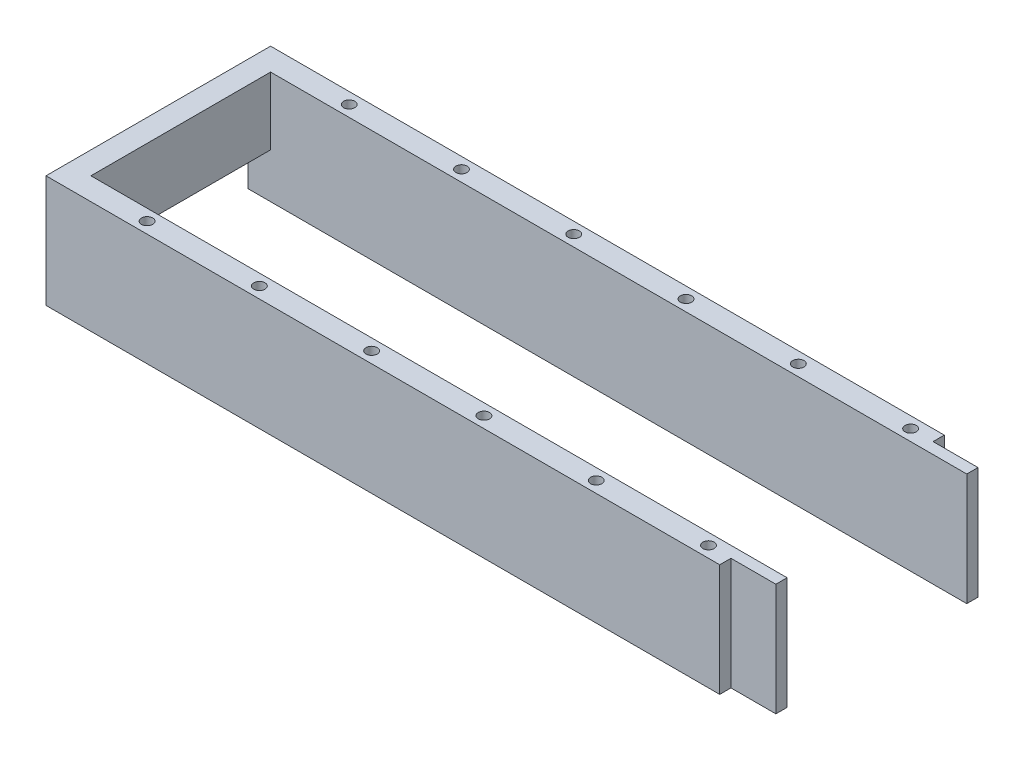
from build123d import *

# Parameters (mm, degrees)
SKETCH2_W           = 203.2
SKETCH2_H           = 6.35
SKETCH2_R           = 1.5875
BOSS_EXTRUDE1_DEPTH = 31.75
SKETCH4_W           = 6.35
SKETCH4_H           = 19.05
BOSS_EXTRUDE2_DEPTH = 50.8
SKETCH6_W           = 12.7
SKETCH6_H           = 3.175
CUT_EXTRUDE1_DEPTH  = 32.75


with BuildPart() as part:
    # Sketch2 → Boss-Extrude1 (new body)
    with BuildSketch(Plane(origin=(0, 0, 0), x_dir=(1, 0, 0), z_dir=(0, 1, 0))):
        Rectangle(SKETCH2_W, SKETCH2_H)
        with Locations((-76.2, 0)):
            Circle(SKETCH2_R, mode=Mode.SUBTRACT)
        with Locations((-44.45, 0)):
            Circle(SKETCH2_R, mode=Mode.SUBTRACT)
        with Locations((-12.7, 0)):
            Circle(SKETCH2_R, mode=Mode.SUBTRACT)
        with Locations((19.05, 0)):
            Circle(SKETCH2_R, mode=Mode.SUBTRACT)
        with Locations((50.8, 0)):
            Circle(SKETCH2_R, mode=Mode.SUBTRACT)
        with Locations((82.55, 0)):
            Circle(SKETCH2_R, mode=Mode.SUBTRACT)
    boss_extrude1 = extrude(amount=BOSS_EXTRUDE1_DEPTH)

    # Sketch4 → Boss-Extrude2 (add)
    with BuildSketch(Plane.XY.offset(3.175)):
        with Locations((-98.425, 22.225)):
            Rectangle(SKETCH4_W, SKETCH4_H)
    extrude(amount=BOSS_EXTRUDE2_DEPTH)

    # Mirror1: Boss-Extrude1 across plane
    add(boss_extrude1.mirror(Plane.XY.offset(28.575)))

    # Sketch6 → Cut-Extrude1 (cut, through all)
    with BuildSketch(Plane(origin=(0, 31.75, 0), x_dir=(1, 0, 0), z_dir=(0, 1, 0))):
        with Locations((95.25, 1.5875)):
            Rectangle(SKETCH6_W, SKETCH6_H)
        with Locations((95.25, -58.7375)):
            Rectangle(SKETCH6_W, SKETCH6_H)
    extrude(amount=-CUT_EXTRUDE1_DEPTH, mode=Mode.SUBTRACT)


solid = part.part
